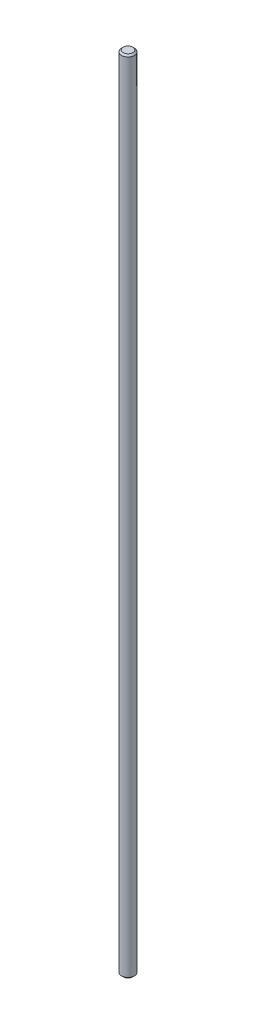
from build123d import *

# Parameters (mm, degrees)
SKETCH1_R           = 4
BOSS_EXTRUDE1_DEPTH = 500
CHAMFER1_SIZE       = 1


with BuildPart() as part:
    # Sketch1 → Boss-Extrude1 (new body)
    with BuildSketch(Plane(origin=(0, 0, 0), x_dir=(1, 0, 0), z_dir=(0, 1, 0))):
        Circle(SKETCH1_R)
    extrude(amount=BOSS_EXTRUDE1_DEPTH)

    # Chamfer1
    chamfer1_edges = [part.edges().sort_by_distance(p)[0] for p in [
        (-4, 0, 0),
        (-4, 500, 0),
    ]]
    chamfer(chamfer1_edges, length=CHAMFER1_SIZE)


solid = part.part
